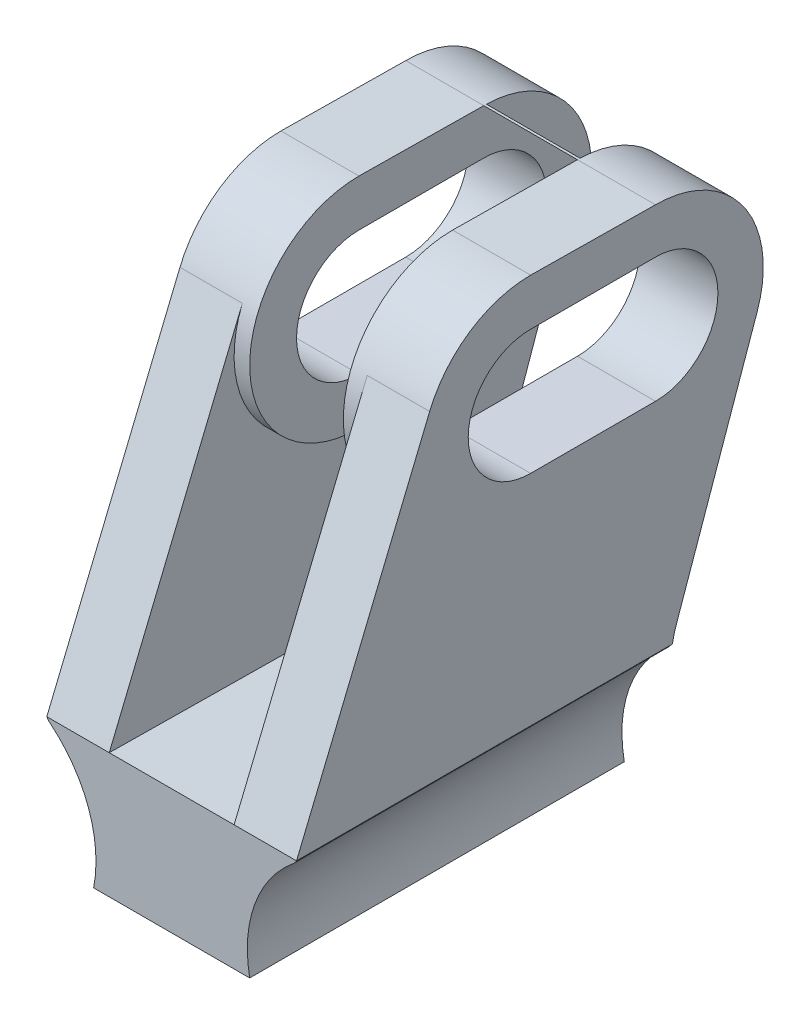
from build123d import *

# Parameters (mm, degrees)
BOSS_EXTRUDE1_DEPTH = 76.2
BOSS_EXTRUDE3_DEPTH = 25.4
SKETCH4_W           = 25.4
SKETCH4_H           = 94.262089718
CUT_EXTRUDE1_DEPTH  = 79.936326
BOSS_EXTRUDE4_START = 12.7
BOSS_EXTRUDE4_DEPTH = 3.175
BOSS_EXTRUDE5_START = -12.7
BOSS_EXTRUDE5_DEPTH = 3.175
SKETCH5_R           = 7.9375
CUT_EXTRUDE2_DEPTH  = 19.05


with BuildPart() as part:
    # Sketch2 → Boss-Extrude1 (new body)
    with BuildSketch(Plane.XY):
        with BuildLine():
            Line((-15.875, 0), (15.875, 0))
            ThreePointArc((15.875, 0), (16.884197435, 13.479245674), (24.665075731, 24.532140152))
            ThreePointArc((24.665075731, 24.532140152), (25.071711114, 24.932897242), (25.4, 25.4))
            Line((25.4, 25.4), (-25.4, 25.4))
            ThreePointArc((-25.4, 25.4), (-25.071711114, 24.932897242), (-24.665075731, 24.532140152))
            ThreePointArc((-24.665075731, 24.532140152), (-16.884197435, 13.479245674), (-15.875, 0))
        make_face()
    extrude(amount=BOSS_EXTRUDE1_DEPTH)

    # Sketch3 → Boss-Extrude3 (add, symmetric)
    with BuildSketch(Plane(origin=(0, 0, 0), x_dir=(0, 0, -1), z_dir=(1, 0, 0))):
        with BuildLine():
            Line((-28.575, 60.325), (-3.175, 60.627395043))
            ThreePointArc((-3.175, 60.627395043), (18.747604957, 82.55), (-3.175, 104.472604957))
            Line((-3.175, 104.472604957), (-28.575, 104.775))
            ThreePointArc((-28.575, 104.775), (-50.8, 82.55), (-28.575, 60.325))
        make_face()
        with BuildLine():
            ThreePointArc((-3.175, 69.85), (9.525, 82.55), (-3.175, 95.25))
            Line((-3.175, 95.25), (-28.575, 95.25))
            ThreePointArc((-28.575, 95.25), (-41.275, 82.55), (-28.575, 69.85))
            Line((-28.575, 69.85), (-3.175, 69.85))
        make_face(mode=Mode.SUBTRACT)
        with BuildLine():
            Line((-76.2, 25.4), (0.270677579, 25.353877505))
            ThreePointArc((0.270677579, 25.353877505), (0.607218741, 26.92535435), (1.075018311, 28.462872802))
            Line((1.075018311, 28.462872802), (17.510481505, 75.289733957))
            ThreePointArc((17.510481505, 75.289733957), (9.502473403, 64.664746962), (-3.175, 60.627395043))
            Line((-3.175, 60.627395043), (-28.575, 60.325))
            ThreePointArc((-28.575, 60.325), (-47.046096671, 70.190015665), (-49.119653814, 91.02748929))
            Line((-49.119653814, 91.02748929), (-76.2, 25.4))
        make_face()
    extrude(amount=BOSS_EXTRUDE3_DEPTH, both=True)

    # Sketch4 → Cut-Extrude1 (cut)
    with BuildSketch(Plane(origin=(0, 104.420005444, -1.243153229), x_dir=(1, 0, 0), z_dir=(0, 0.999929139, -0.011904473))):
        with Locations((0, -29.365929167)):
            Rectangle(SKETCH4_W, SKETCH4_H)
    extrude(amount=-CUT_EXTRUDE1_DEPTH, mode=Mode.SUBTRACT)

    # Sketch3_7 → Boss-Extrude4 (add)
    with BuildSketch(Plane(origin=(0, 0, 0), x_dir=(0, 0, -1), z_dir=(1, 0, 0)).offset(BOSS_EXTRUDE4_START)):
        with BuildLine():
            Line((-28.575, 60.325), (-3.175, 60.627395043))
            ThreePointArc((-3.175, 60.627395043), (18.747604957, 82.55), (-3.175, 104.472604957))
            Line((-3.175, 104.472604957), (-28.575, 104.775))
            ThreePointArc((-28.575, 104.775), (-50.8, 82.55), (-28.575, 60.325))
        make_face()
        with BuildLine():
            ThreePointArc((-3.175, 69.85), (9.525, 82.55), (-3.175, 95.25))
            Line((-3.175, 95.25), (-28.575, 95.25))
            ThreePointArc((-28.575, 95.25), (-41.275, 82.55), (-28.575, 69.85))
            Line((-28.575, 69.85), (-3.175, 69.85))
        make_face(mode=Mode.SUBTRACT)
    extrude(amount=-BOSS_EXTRUDE4_DEPTH)

    # Sketch3_8 → Boss-Extrude5 (add)
    with BuildSketch(Plane(origin=(0, 0, 0), x_dir=(0, 0, -1), z_dir=(1, 0, 0)).offset(BOSS_EXTRUDE5_START)):
        with BuildLine():
            Line((-28.575, 60.325), (-3.175, 60.627395043))
            ThreePointArc((-3.175, 60.627395043), (18.747604957, 82.55), (-3.175, 104.472604957))
            Line((-3.175, 104.472604957), (-28.575, 104.775))
            ThreePointArc((-28.575, 104.775), (-50.8, 82.55), (-28.575, 60.325))
        make_face()
        with BuildLine():
            ThreePointArc((-3.175, 69.85), (9.525, 82.55), (-3.175, 95.25))
            Line((-3.175, 95.25), (-28.575, 95.25))
            ThreePointArc((-28.575, 95.25), (-41.275, 82.55), (-28.575, 69.85))
            Line((-28.575, 69.85), (-3.175, 69.85))
        make_face(mode=Mode.SUBTRACT)
    extrude(amount=BOSS_EXTRUDE5_DEPTH)

    # Sketch5 → Cut-Extrude2 (cut)
    with BuildSketch(Plane.XZ):
        with Locations((0, 52.3875)):
            Circle(SKETCH5_R)
        with Locations((0, 23.8125)):
            Circle(SKETCH5_R)
    extrude(amount=-CUT_EXTRUDE2_DEPTH, mode=Mode.SUBTRACT)


solid = part.part
